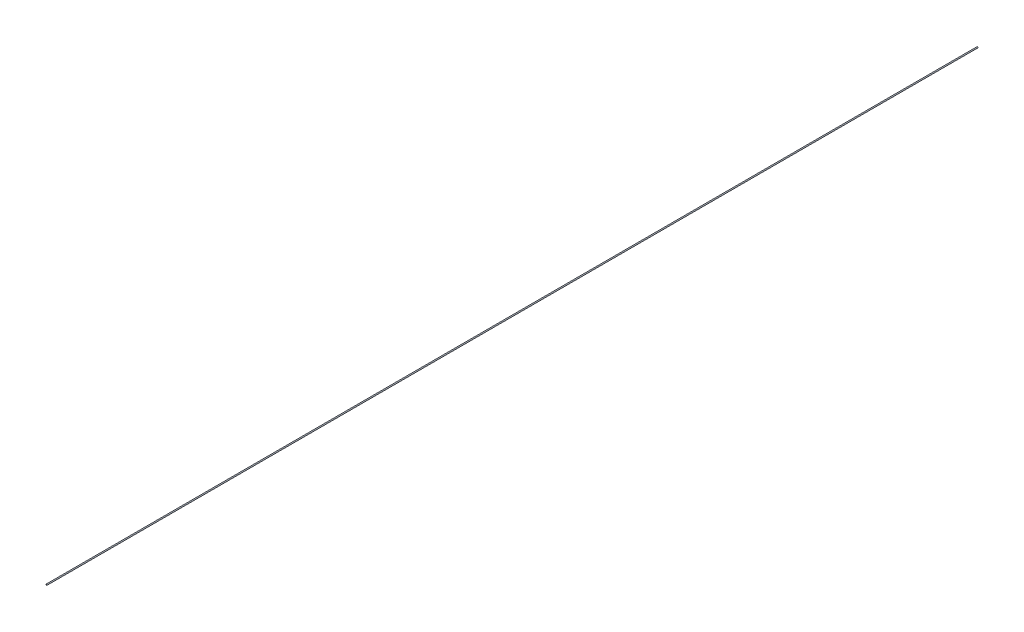
from build123d import *

# Parameters (mm, degrees)
SKETCH2_R           = 6.35
SKETCH2_R_2         = 5.334
BOSS_EXTRUDE1_DEPTH = 11125.2


with BuildPart() as part:
    # Sketch2 → Boss-Extrude1 (new body)
    with BuildSketch(Plane.XY):
        Circle(SKETCH2_R)
        Circle(SKETCH2_R_2, mode=Mode.SUBTRACT)
    extrude(amount=BOSS_EXTRUDE1_DEPTH)


solid = part.part
